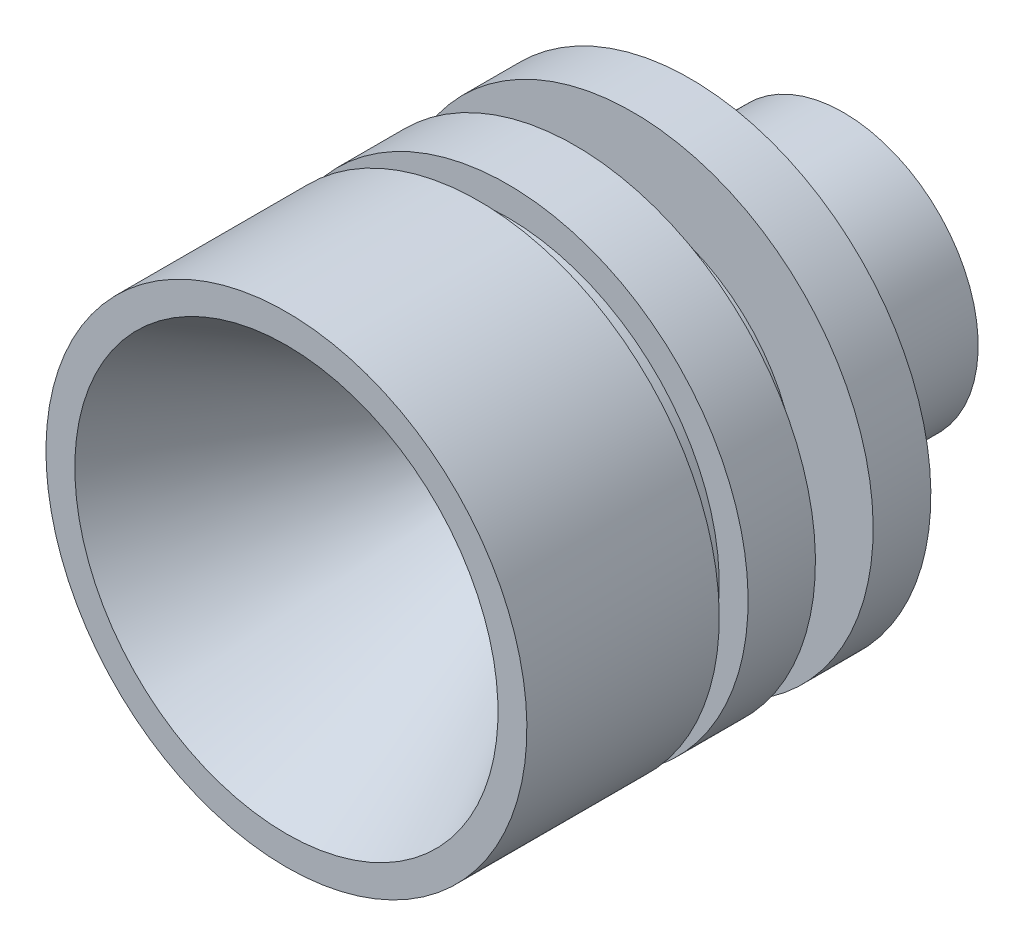
from build123d import *


with BuildPart() as part:
    # Esquisse1 → Révolution1 (revolve)
    with BuildSketch(Plane(origin=(0, 0, 0), x_dir=(0, 0, -1), z_dir=(1, 0, 0))):
        Polygon((-14.479601386, 12.5), (-4.479601386, 12.5), (-4.479601386, 11), (-2.979601386, 11), (-2.979601386, 12.5), (0.520398614, 12.5), (0.520398614, 8.5), (3.520398614, 8.5), (3.520398614, 12.5), (6.520398614, 12.5), (6.520398614, 7), (14.479601386, 7), (14.479601386, 4.5), (1.541868584, 1.75), (-14.479601386, 11), align=None)
    revolve(axis=Axis((0, 0, 14.479601386), (0, 0, -1)))


solid = part.part
